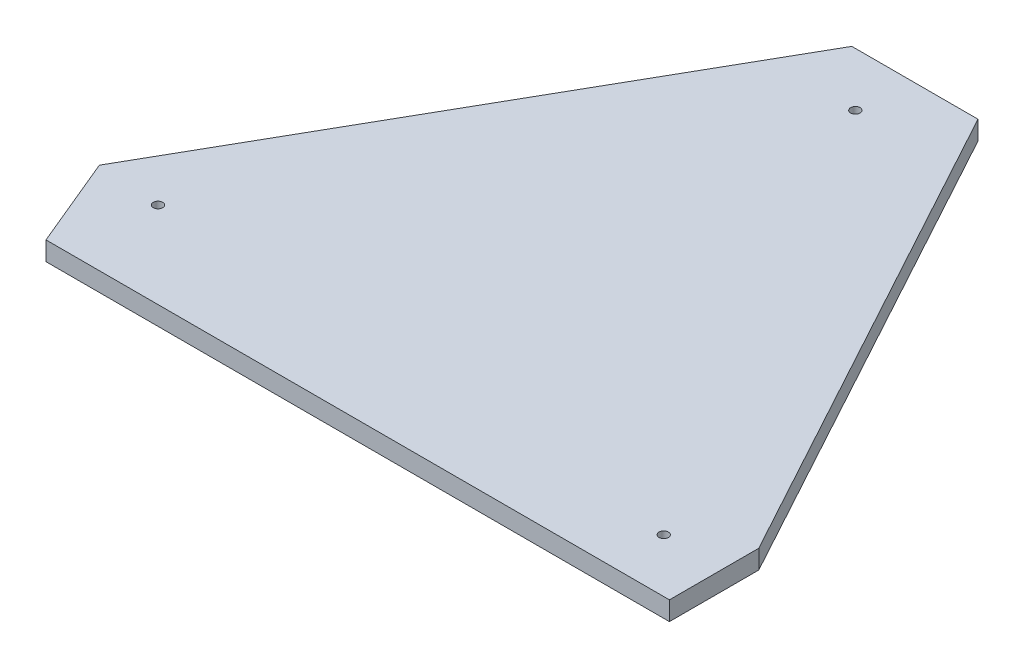
from build123d import *

# Parameters (mm, degrees)
BOSS_EXTRUDE1_DEPTH = 15.875
SKETCH2_R           = 3.96875
CUT_EXTRUDE1_DEPTH  = 16.875


with BuildPart() as part:
    # Sketch1 → Boss-Extrude1 (new body)
    with BuildSketch(Plane(origin=(0, 0, 0), x_dir=(1, 0, 0), z_dir=(0, 1, 0))):
        Polygon((0, 0), (-523.875, 0), (-555.849378124, 76.79442277), (-326.138209959, 479.425), (-220.118609959, 479.425), (0, 75.0824), align=None)
    extrude(amount=BOSS_EXTRUDE1_DEPTH)

    # Sketch2 → Cut-Extrude1 (cut, through all)
    with BuildSketch(Plane(origin=(0, 15.875, 0), x_dir=(1, 0, 0), z_dir=(0, 1, 0))):
        with Locations((-278.106809959, 434.34)):
            Circle(SKETCH2_R)
        with Locations((-502.204578124, 72.4408)):
            Circle(SKETCH2_R)
        with Locations((-49.7332, 44.9326)):
            Circle(SKETCH2_R)
    extrude(amount=-CUT_EXTRUDE1_DEPTH, mode=Mode.SUBTRACT)


solid = part.part
